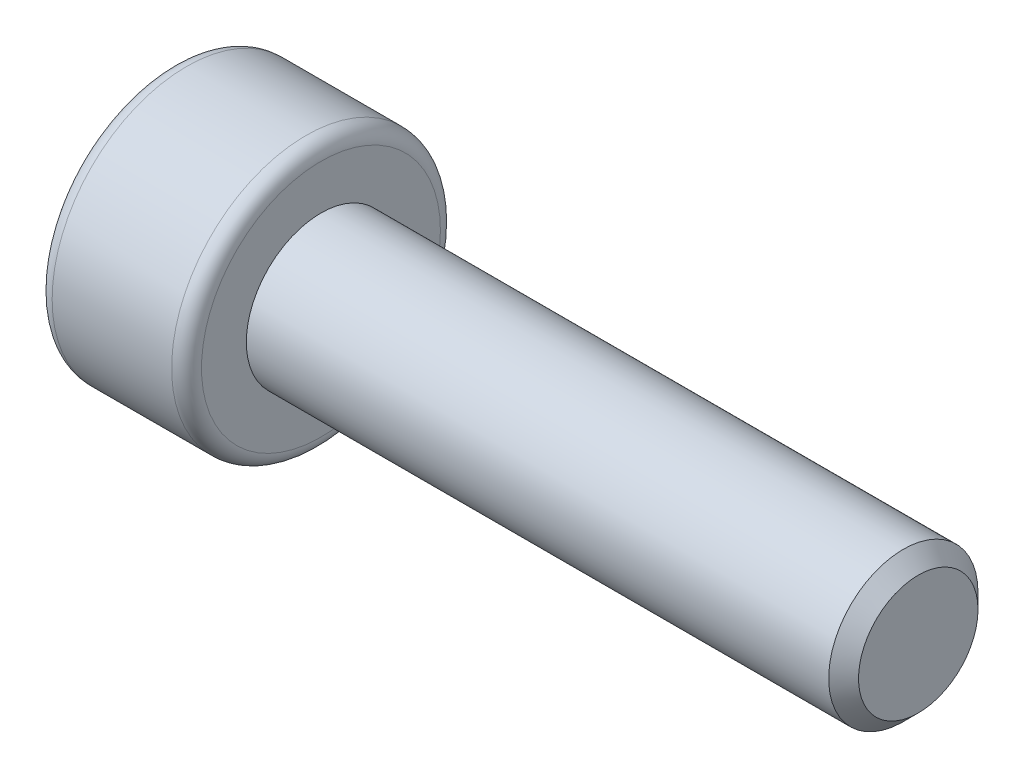
from build123d import *

# Parameters (mm, degrees)
CUT_EXTRUDE_1_DEPTH = 1.5
FILLET_1_R          = 0.2
CHAMFER_1_SIZE      = 0.2


with BuildPart() as part:
    # 草图1 → 旋转1 (revolve)
    with BuildSketch(Plane.XY):
        Polygon((-5, 0), (-5, 1.8), (-3, 1.8), (-3, 1), (5, 1), (5, 0), align=None)
    revolve(axis=Axis((5, 0, 0), (-1, 0, 0)))

    # 草图2 → 切除-拉伸1 (cut)
    with BuildSketch(Plane.ZY.offset(5)):
        Polygon((0.866025404, 0), (0.433012702, 0.75), (-0.433012702, 0.75), (-0.866025404, 0), (-0.433012702, -0.75), (0.433012702, -0.75), align=None)
    extrude(amount=-CUT_EXTRUDE_1_DEPTH, mode=Mode.SUBTRACT)

    # 圆角1
    fillet_1_edges = [part.edges().sort_by_distance(p)[0] for p in [
        (-3, -1.8, 0),
        (-5, -1.8, 0),
    ]]
    fillet(fillet_1_edges, radius=FILLET_1_R)

    # 倒角1
    chamfer_1_edges = [part.edges().sort_by_distance(p)[0] for p in [
        (5, -1, 0),
    ]]
    chamfer(chamfer_1_edges, length=CHAMFER_1_SIZE)


solid = part.part
